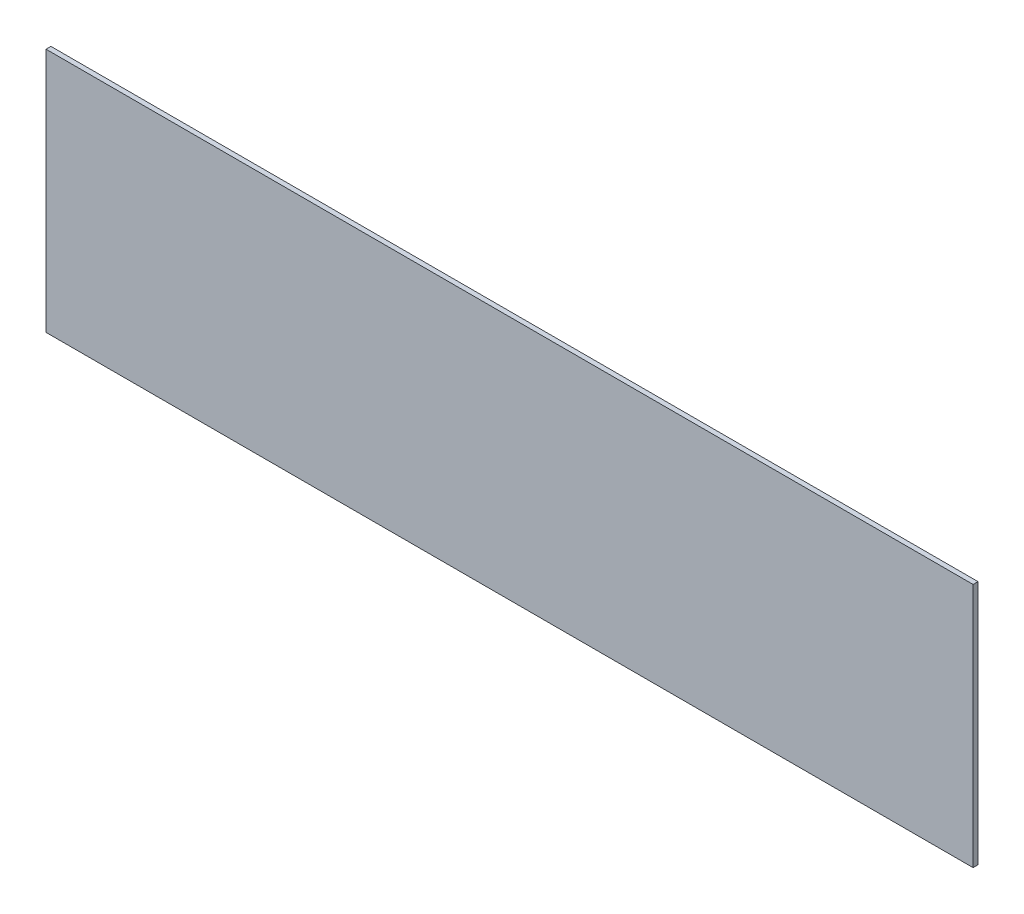
from build123d import *

# Parameters (mm, degrees)
SKETCH1_W           = 189
SKETCH1_H           = 50
BOSS_EXTRUDE1_DEPTH = 1


with BuildPart() as part:
    # Sketch1 → Boss-Extrude1 (new body)
    with BuildSketch(Plane.XY):
        with Locations((32.350547407, 31.922852407)):
            Rectangle(SKETCH1_W, SKETCH1_H)
    extrude(amount=BOSS_EXTRUDE1_DEPTH)


solid = part.part
